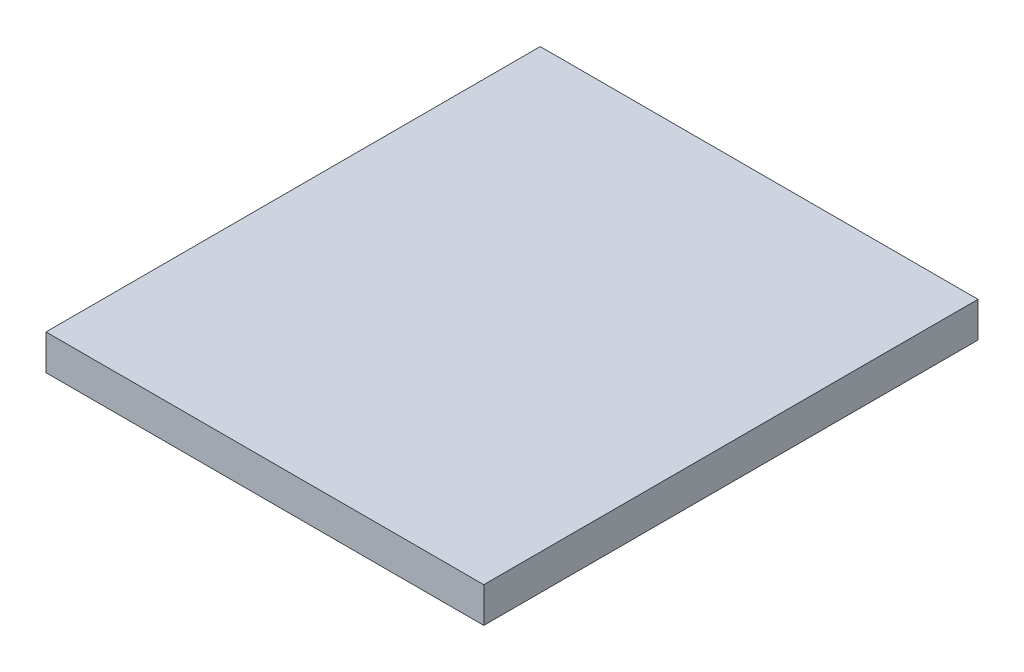
from build123d import *

# Parameters (mm, degrees)
SZKIC1_W                    = 124
SZKIC1_H                    = 140
DODANIE_WYCI_GNI_CIE1_DEPTH = 1
DODANIE_WYCI_GNI_CIE2_DEPTH = 10


with BuildPart() as part:
    # Szkic1 → Dodanie-wyciągnięcie1 (new body)
    with BuildSketch(Plane(origin=(0, 0, 0), x_dir=(1, 0, 0), z_dir=(0, 1, 0))):
        with Locations((62, -70)):
            Rectangle(SZKIC1_W, SZKIC1_H)
    extrude(amount=DODANIE_WYCI_GNI_CIE1_DEPTH)

    # Szkic3 → Dodanie-wyciągnięcie2 (add)
    with BuildSketch(Plane(origin=(0, 1, 0), x_dir=(1, 0, 0), z_dir=(0, 1, 0))):
        Polygon((0, 0), (0, -140), (124, -140), (124, 0), (123, 0), (123, -139), (1, -139), (1, 0), align=None)
    extrude(amount=-DODANIE_WYCI_GNI_CIE2_DEPTH)


solid = part.part
